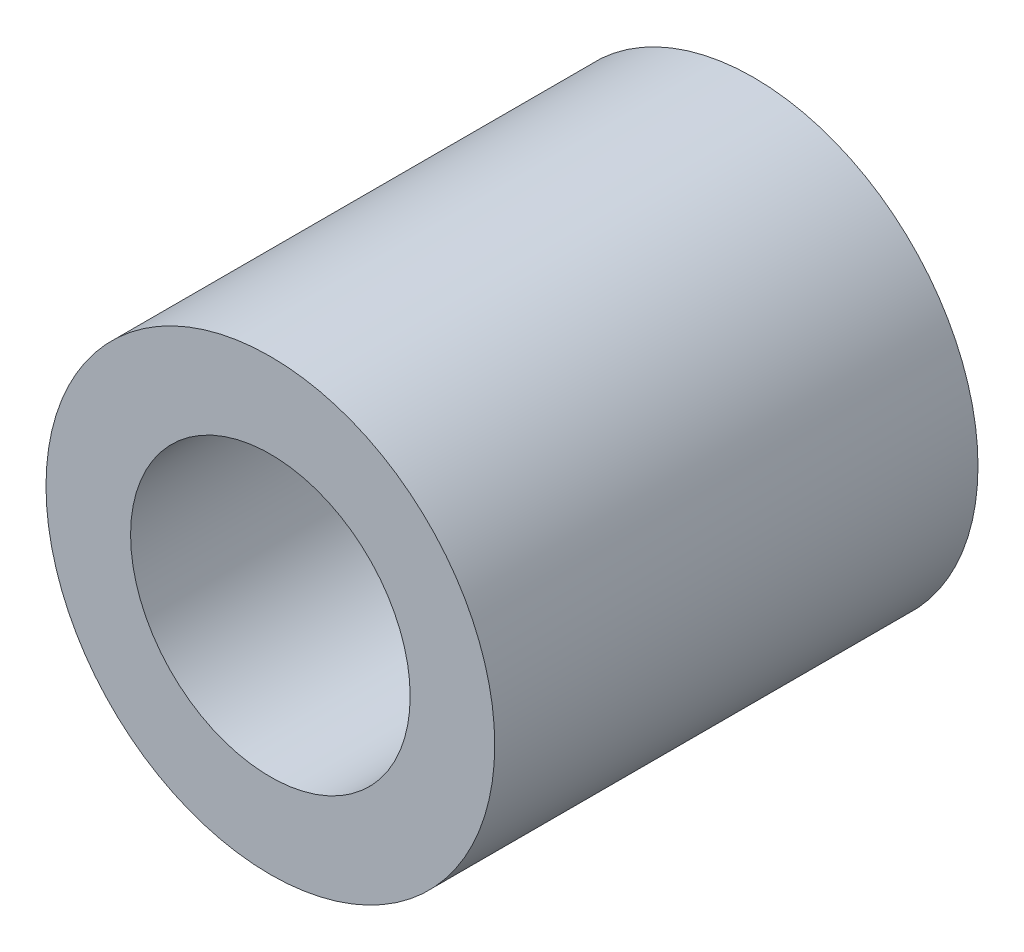
from build123d import *

# Parameters (mm, degrees)
CROQUIS1_R              = 6.5
CROQUIS1_R_2            = 4.05
SALIENTE_EXTRUIR1_DEPTH = 14


with BuildPart() as part:
    # Croquis1 → Saliente-Extruir1 (new body)
    with BuildSketch(Plane.XY):
        Circle(CROQUIS1_R)
        Circle(CROQUIS1_R_2, mode=Mode.SUBTRACT)
    extrude(amount=SALIENTE_EXTRUIR1_DEPTH)


solid = part.part
